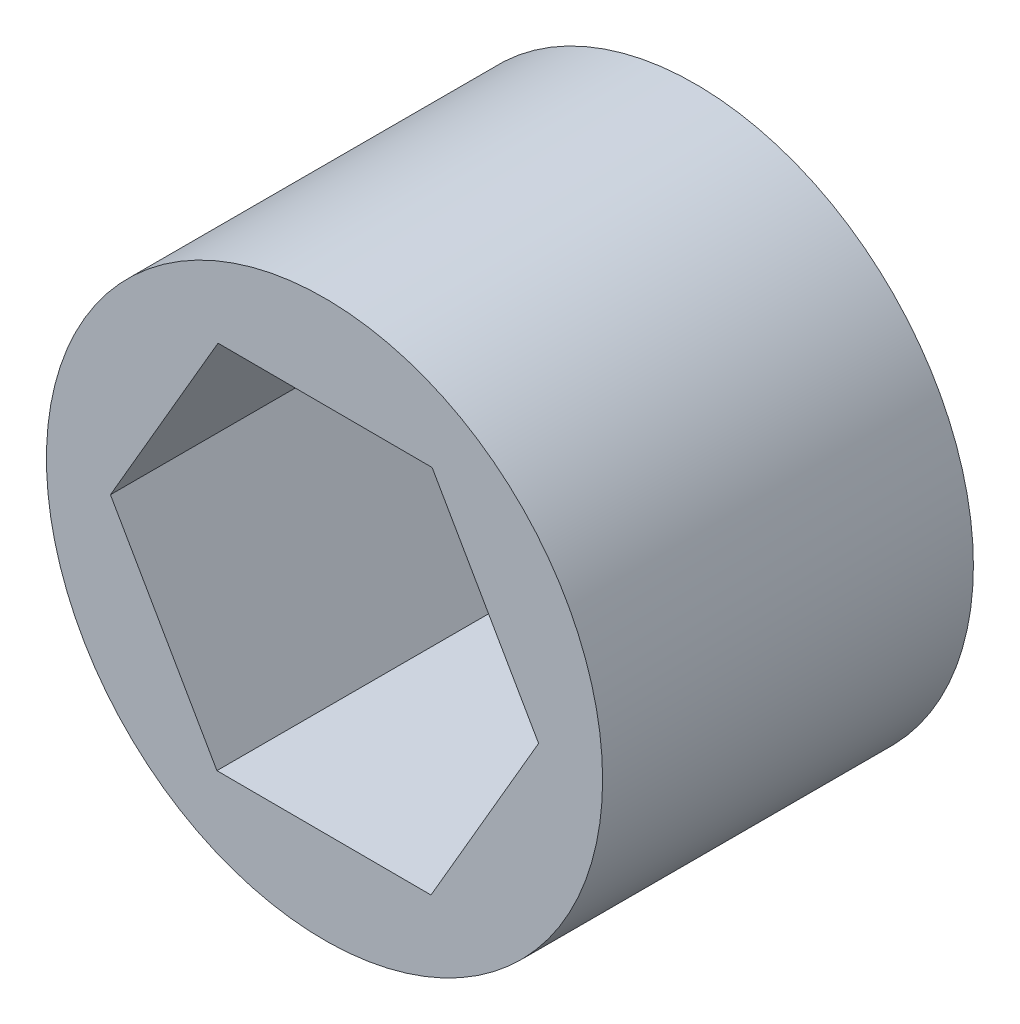
from build123d import *

# Parameters (mm, degrees)
SKETCH1_R           = 9.525
BOSS_EXTRUDE1_DEPTH = 12.7


with BuildPart() as part:
    # Sketch1 → Boss-Extrude1 (new body)
    with BuildSketch(Plane.XY):
        Circle(SKETCH1_R)
        Polygon((3.64699361, -6.361035367), (7.332315027, -0.022128569), (3.685321417, 6.338906797), (-3.64699361, 6.361035367), (-7.332315027, 0.022128569), (-3.685321417, -6.338906797), align=None, mode=Mode.SUBTRACT)
    extrude(amount=BOSS_EXTRUDE1_DEPTH)


solid = part.part
